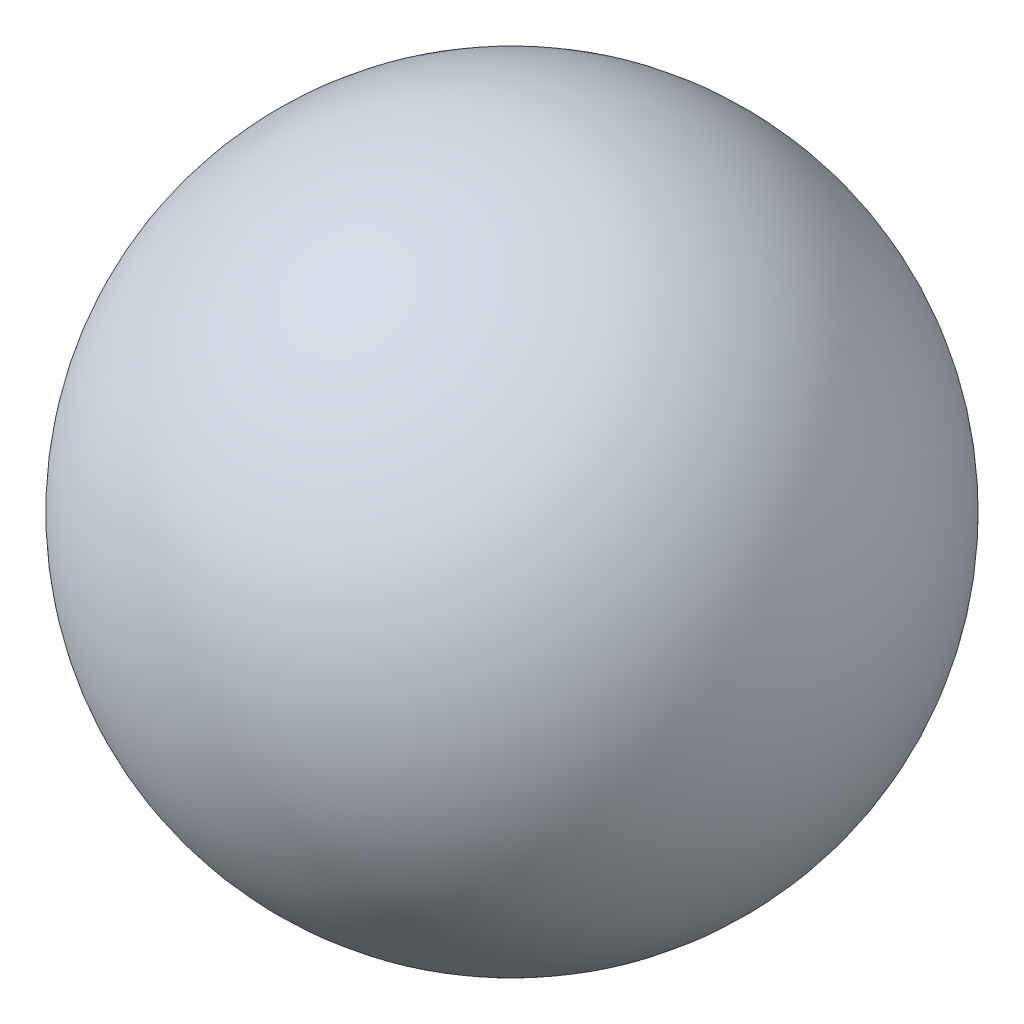
from build123d import *


with BuildPart() as part:
    # Sketch2 → Revolve1 (revolve)
    with BuildSketch(Plane(origin=(0, 0, 0), x_dir=(0, 0, -1), z_dir=(1, 0, 0))):
        with BuildLine():
            Line((0, 247.65), (0, 0))
            ThreePointArc((0, 0), (123.825, 123.825), (0, 247.65))
        make_face()
    revolve(axis=Axis((0, 247.65, 0), (0, -1, 0)))


solid = part.part
